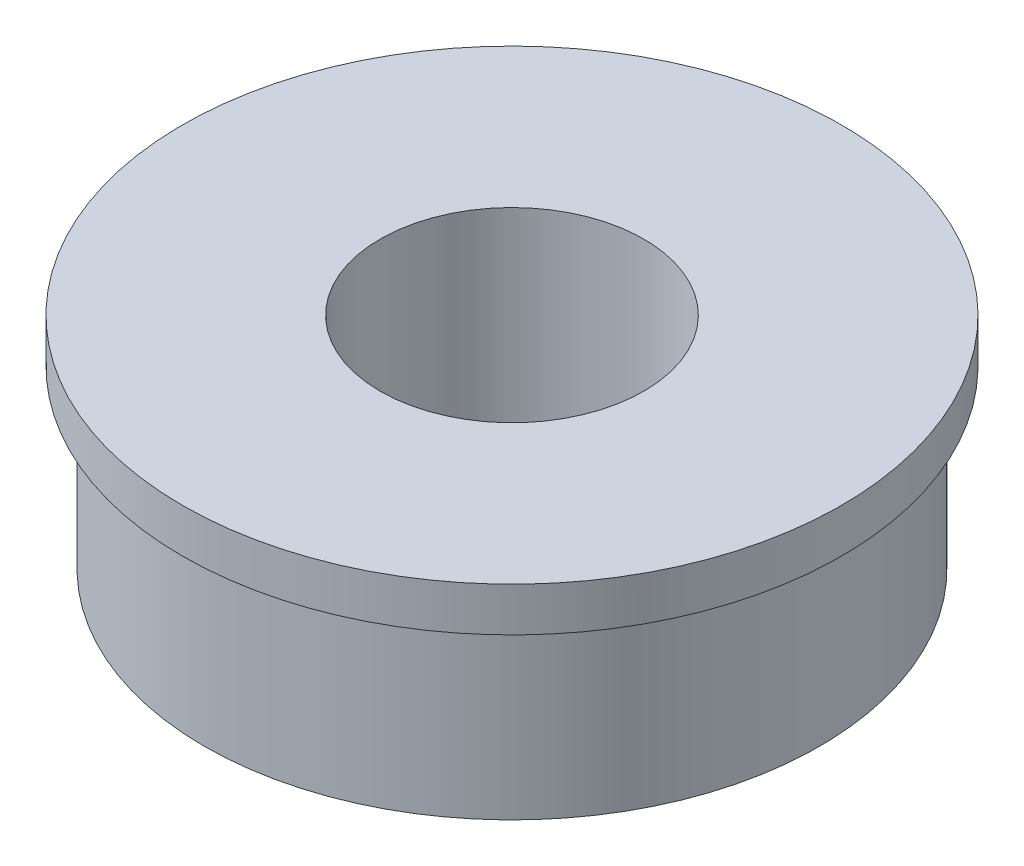
from build123d import *

# Parameters (mm, degrees)
SKETCH1_R           = 7.5
SKETCH1_R_2         = 3
BOSS_EXTRUDE1_DEPTH = 5
SKETCH2_R           = 7.5
SKETCH2_R_2         = 7
CUT_EXTRUDE2_DEPTH  = 4


with BuildPart() as part:
    # Sketch1 → Boss-Extrude1 (new body)
    with BuildSketch(Plane(origin=(0, 0, 0), x_dir=(1, 0, 0), z_dir=(0, 1, 0))):
        Circle(SKETCH1_R)
        Circle(SKETCH1_R_2, mode=Mode.SUBTRACT)
    extrude(amount=-BOSS_EXTRUDE1_DEPTH)

    # Sketch2 → Cut-Extrude2 (cut)
    with BuildSketch(Plane.XZ.offset(5)):
        Circle(SKETCH2_R)
        Circle(SKETCH2_R_2, mode=Mode.SUBTRACT)
    extrude(amount=-CUT_EXTRUDE2_DEPTH, mode=Mode.SUBTRACT)


solid = part.part
